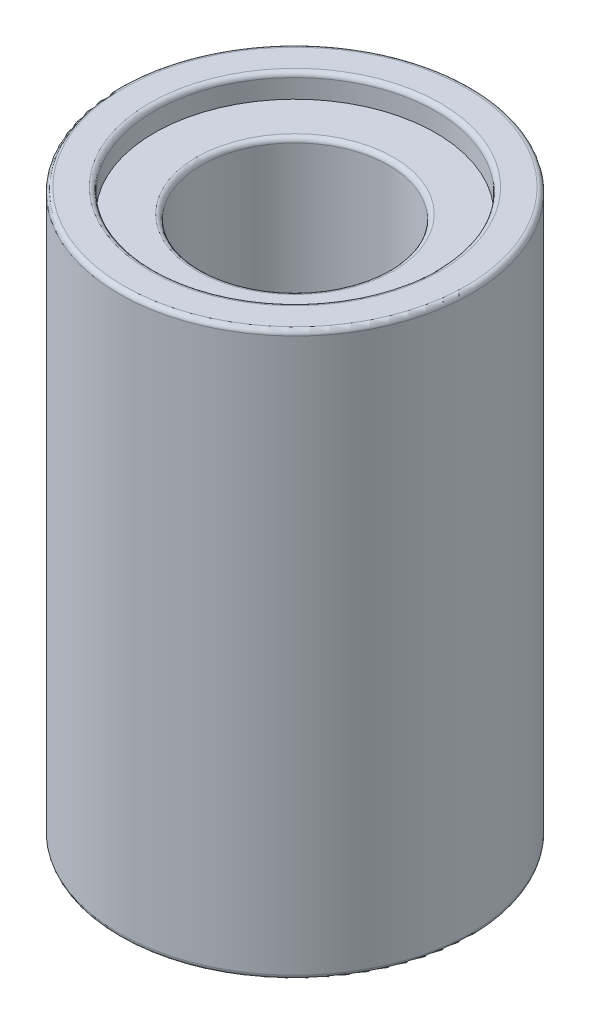
from build123d import *

# Parameters (mm, degrees)
SKETCH1_R           = 7.5
SKETCH1_R_2         = 6
BOSS_EXTRUDE1_DEPTH = 24
SKETCH2_R           = 6
SKETCH2_R_2         = 4
BOSS_EXTRUDE2_DEPTH = 22
FILLET1_R           = 0.2


with BuildPart() as part:
    # Sketch1 → Boss-Extrude1 (new body)
    with BuildSketch(Plane(origin=(0, 0, 0), x_dir=(1, 0, 0), z_dir=(0, 1, 0))):
        Circle(SKETCH1_R)
        Circle(SKETCH1_R_2, mode=Mode.SUBTRACT)
    extrude(amount=BOSS_EXTRUDE1_DEPTH)

    # Sketch2 → Boss-Extrude2 (add)
    with BuildSketch(Plane(origin=(0, 23, 0), x_dir=(1, 0, 0), z_dir=(0, 1, 0))):
        Circle(SKETCH2_R)
        Circle(SKETCH2_R_2, mode=Mode.SUBTRACT)
    extrude(amount=-BOSS_EXTRUDE2_DEPTH)

    # Fillet1
    fillet1_edges = [part.edges().sort_by_distance(p)[0] for p in [
        (-4, 1, 0),
        (-4, 23, 0),
        (-7.5, 0, 0),
        (-7.5, 24, 0),
        (-6, 0, 0),
        (-6, 24, 0),
    ]]
    fillet(fillet1_edges, radius=FILLET1_R)


solid = part.part
